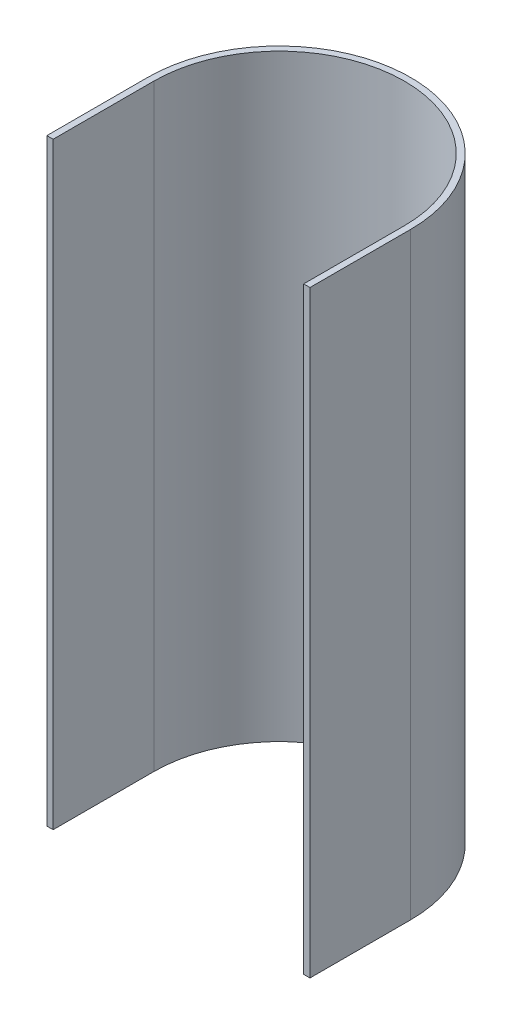
from build123d import *

# Parameters (mm, degrees)
BOSS_EXTRUDE1_DEPTH = 18
BOSS_EXTRUDE2_START = -1
BOSS_EXTRUDE2_DEPTH = 1


with BuildPart() as part:
    # Sketch1 → Boss-Extrude1 (new body)
    with BuildSketch(Plane(origin=(0, 0, 0), x_dir=(1, 0, 0), z_dir=(0, 1, 0))):
        with BuildLine():
            ThreePointArc((30.88932948, 3), (26.70932948, 7.18), (22.52932948, 3))
            Line((22.52932948, 3), (22.52932948, 0))
            Line((22.52932948, 0), (22.52932948, -0.2))
            Line((22.52932948, -0.2), (22.72932948, -0.2))
            Line((22.72932948, -0.2), (22.72932948, 0))
            Line((22.72932948, 0), (22.72932948, 3))
            ThreePointArc((22.72932948, 3), (26.70932948, 6.98), (30.68932948, 3))
            Line((30.68932948, 3), (30.68932948, 0))
            Line((30.68932948, 0), (30.68932948, -0.2))
            Line((30.68932948, -0.2), (30.88932948, -0.2))
            Line((30.88932948, -0.2), (30.88932948, 0))
            Line((30.88932948, 0), (30.88932948, 3))
        make_face()
    extrude(amount=BOSS_EXTRUDE1_DEPTH)

    # Sketch1_4 → Boss-Extrude2 (add)
    with BuildSketch(Plane(origin=(0, 0, 0), x_dir=(1, 0, 0), z_dir=(0, 1, 0)).offset(BOSS_EXTRUDE2_START)):
        with BuildLine():
            ThreePointArc((30.88932948, 3), (26.70932948, 7.18), (22.52932948, 3))
            Line((22.52932948, 3), (22.52932948, 0))
            Line((22.52932948, 0), (22.52932948, -0.2))
            Line((22.52932948, -0.2), (22.72932948, -0.2))
            Line((22.72932948, -0.2), (22.72932948, 0))
            Line((22.72932948, 0), (22.72932948, 3))
            ThreePointArc((22.72932948, 3), (26.70932948, 6.98), (30.68932948, 3))
            Line((30.68932948, 3), (30.68932948, 0))
            Line((30.68932948, 0), (30.68932948, -0.2))
            Line((30.68932948, -0.2), (30.88932948, -0.2))
            Line((30.88932948, -0.2), (30.88932948, 0))
            Line((30.88932948, 0), (30.88932948, 3))
        make_face()
    extrude(amount=BOSS_EXTRUDE2_DEPTH)


solid = part.part
